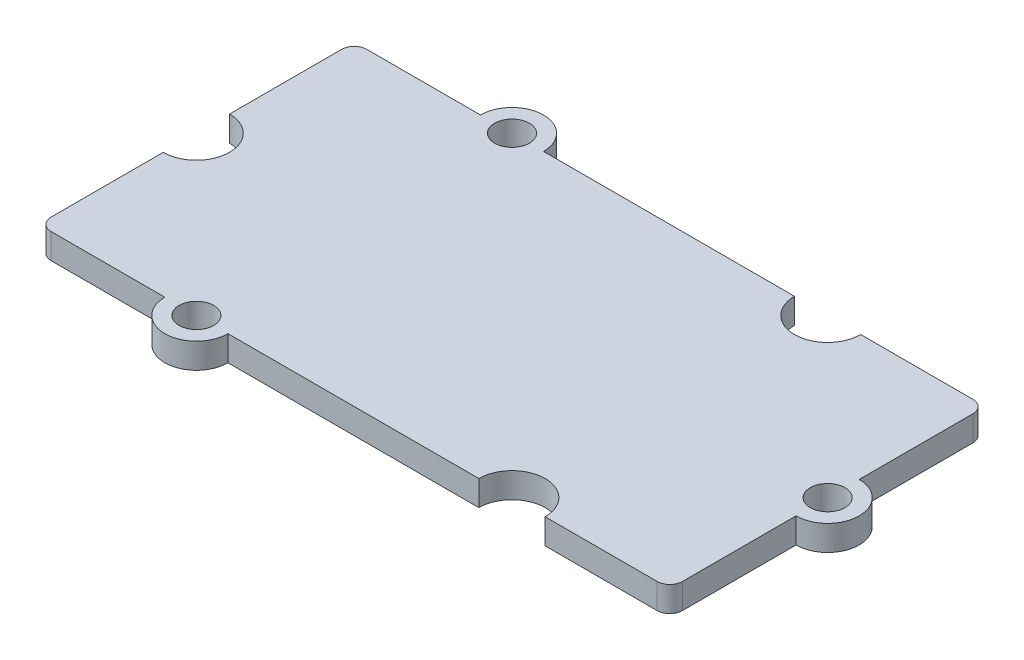
from build123d import *

# Parameters (mm, degrees)
ESQUISSE1_R        = 1.1
BOSS_EXTRU_1_DEPTH = 0.8


with BuildPart() as part:
    # Esquisse1 → Boss.-Extru.1 (new body, symmetric)
    with BuildSketch(Plane(origin=(0, 0, 0), x_dir=(1, 0, 0), z_dir=(0, 1, 0))):
        with BuildLine():
            ThreePointArc((-12, -10), (-10, -12), (-8, -10))
            Line((-8, -10), (7.9, -10))
            ThreePointArc((7.9, -10), (10, -7.9), (12.1, -10))
            Line((12.1, -10), (19.2, -10))
            ThreePointArc((19.2, -10), (19.765685425, -9.765685425), (20, -9.2))
            Line((20, -9.2), (20, -2))
            ThreePointArc((20, -2), (22, 0), (20, 2))
            Line((20, 2), (20, 9.2))
            ThreePointArc((20, 9.2), (19.765685425, 9.765685425), (19.2, 10))
            Line((19.2, 10), (12.1, 10))
            ThreePointArc((12.1, 10), (10, 7.9), (7.9, 10))
            Line((7.9, 10), (-8, 10))
            ThreePointArc((-8, 10), (-10, 12), (-12, 10))
            Line((-12, 10), (-19.2, 10))
            ThreePointArc((-19.2, 10), (-19.765685425, 9.765685425), (-20, 9.2))
            Line((-20, 9.2), (-20, 2.1))
            ThreePointArc((-20, 2.1), (-17.9, 0), (-20, -2.1))
            Line((-20, -2.1), (-20, -9.2))
            ThreePointArc((-20, -9.2), (-19.765685425, -9.765685425), (-19.2, -10))
            Line((-19.2, -10), (-12, -10))
        make_face()
        with Locations((-10, -10)):
            Circle(ESQUISSE1_R, mode=Mode.SUBTRACT)
        with Locations((20, 0)):
            Circle(ESQUISSE1_R, mode=Mode.SUBTRACT)
        with Locations((-10, 10)):
            Circle(ESQUISSE1_R, mode=Mode.SUBTRACT)
    extrude(amount=BOSS_EXTRU_1_DEPTH, both=True)


solid = part.part
